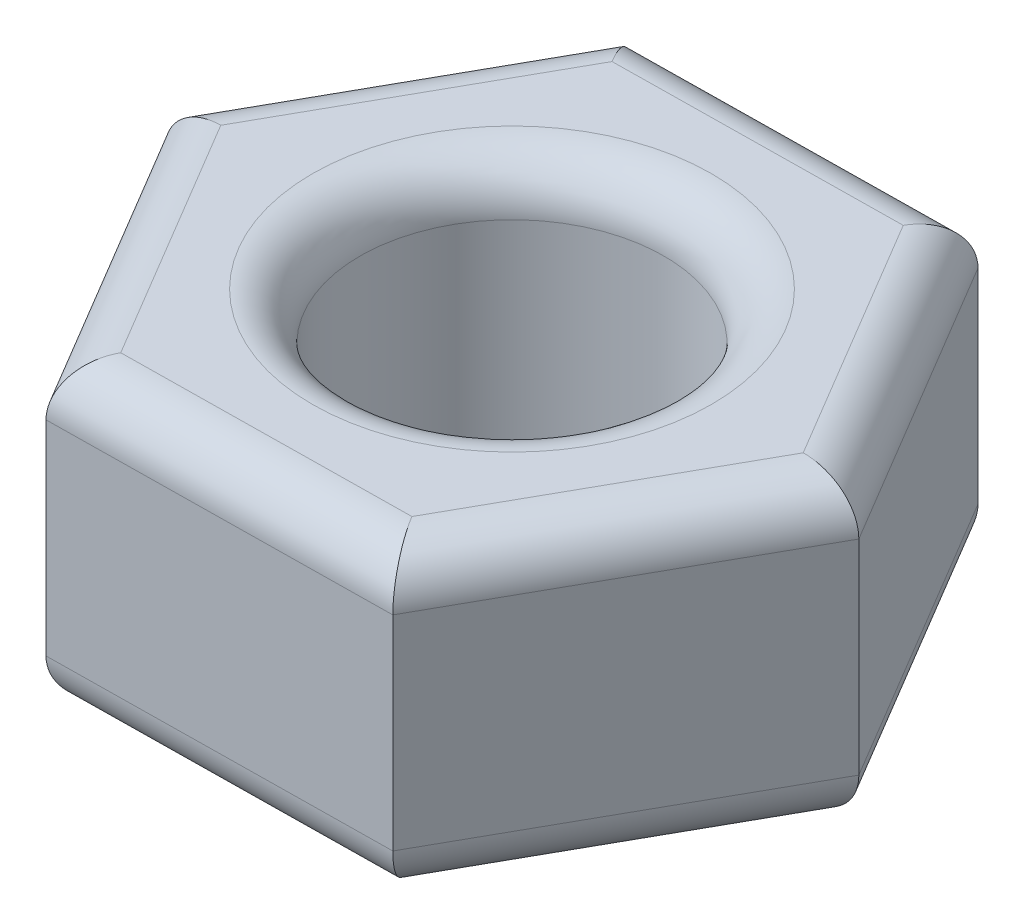
from build123d import *

# Parameters (mm, degrees)
SKETCH1_R           = 3.2
BOSS_EXTRUDE1_DEPTH = 6.3
FILLET1_R           = 1


with BuildPart() as part:
    # Sketch1 → Boss-Extrude1 (new body)
    with BuildSketch(Plane(origin=(0, 0, 0), x_dir=(1, 0, 0), z_dir=(0, 1, 0))):
        Polygon((-3.681439065, 6.187649506), (-7.199381195, -0.094395), (-3.517942129, -6.282044506), (3.681439065, -6.187649506), (7.199381195, 0.094395), (3.517942129, 6.282044506), align=None)
        with Locations(Location((0, 0, 0), (0, 0, 270))):  # turned: the seam where the file's is
            Circle(SKETCH1_R, mode=Mode.SUBTRACT)
    extrude(amount=BOSS_EXTRUDE1_DEPTH)

    # Fillet1
    fillet1_edges = [part.edges().sort_by_distance(p)[0] for p in [
        (-5.358661662, 6.3, 3.188219753),
        (0.081748468, 6.3, 6.234847006),
        (5.44041013, 6.3, 3.046627253),
        (0, 0, -3.2),
        (0, 6.3, -3.2),
        (5.358661662, 6.3, -3.188219753),
        (-0.081748468, 6.3, -6.234847006),
        (5.358661662, 0, -3.188219753),
        (5.44041013, 0, 3.046627253),
        (0.081748468, 0, 6.234847006),
        (-5.44041013, 6.3, -3.046627253),
        (-5.358661662, 0, 3.188219753),
        (-5.44041013, 0, -3.046627253),
        (-0.081748468, 0, -6.234847006),
    ]]
    fillet(fillet1_edges, radius=FILLET1_R)


solid = part.part
